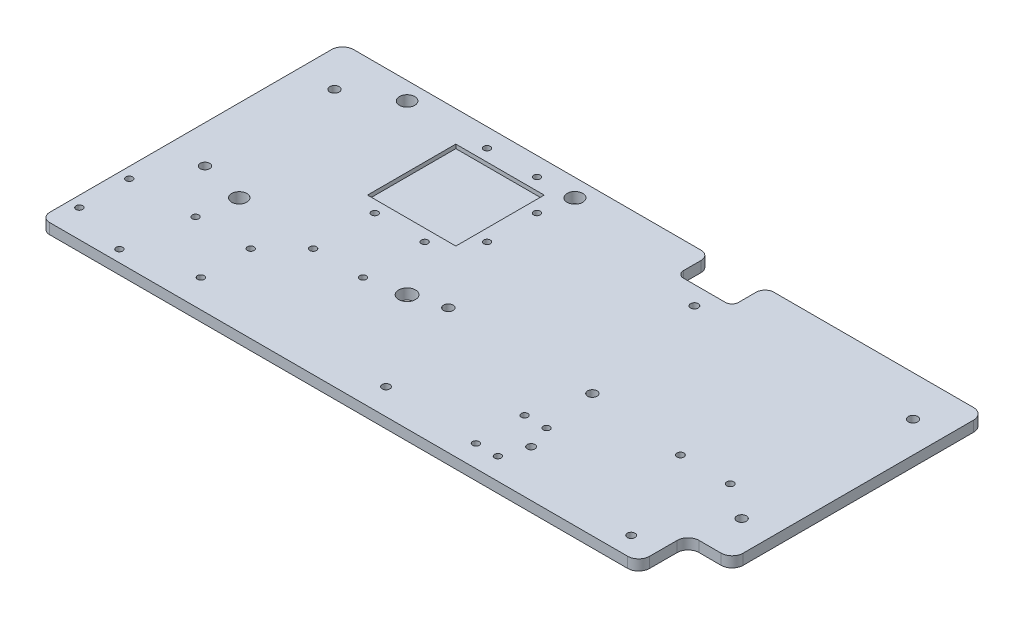
from build123d import *

# Parameters (mm, degrees)
SKETCH1_R           = 3.441866939
SKETCH1_R_2         = 3.819680327
SKETCH1_R_3         = 3.478478145
SKETCH1_R_4         = 3.546045212
SKETCH1_R_5         = 2.15
SKETCH1_R_6         = 1.75
SKETCH1_R_7         = 1.6
SKETCH1_R_8         = 1.5
BOSS_EXTRUDE1_DEPTH = 4.8
SKETCH8_W           = 40.1
SKETCH8_H           = 40.1
CUT_EXTRUDE3_DEPTH  = 1.8


with BuildPart() as part:
    # Sketch1 → Boss-Extrude1 (new body)
    with BuildSketch(Plane(origin=(0, 0, 0), x_dir=(1, 0, 0), z_dir=(0, 1, 0))):
        with BuildLine():
            Line((245, 5), (245, 17.432639589))
            ThreePointArc((245, 17.432639589), (246.464466094, 20.968173495), (250, 22.432639589))
            Line((250, 22.432639589), (260, 22.432639589))
            ThreePointArc((260, 22.432639589), (263.535533906, 23.897105683), (265, 27.432639589))
            Line((265, 27.432639589), (265, 132))
            ThreePointArc((265, 132), (263.535533906, 135.535533906), (260, 137))
            Line((260, 137), (169.363043016, 137))
            ThreePointArc((169.363043016, 137), (166.534615891, 135.828427125), (165.363043016, 133))
            Line((165.363043016, 133), (165.363043016, 125))
            ThreePointArc((165.363043016, 125), (164.48436336, 122.878679656), (162.363043016, 122))
            Line((162.363043016, 122), (143.363043016, 122))
            ThreePointArc((143.363043016, 122), (141.241722673, 122.878679656), (140.363043016, 125))
            Line((140.363043016, 125), (140.363043016, 133))
            ThreePointArc((140.363043016, 133), (139.191470141, 135.828427125), (136.363043016, 137))
            Line((136.363043016, 137), (-21.419472962, 137))
            ThreePointArc((-21.419472962, 137), (-24.955006868, 135.535533906), (-26.419472962, 132))
            Line((-26.419472962, 132), (-26.419472962, 4))
            ThreePointArc((-26.419472962, 4), (-25.247900086, 1.171572875), (-22.419472962, 0))
            Line((-22.419472962, 0), (0, 0))
            Line((0, 0), (240, 0))
            ThreePointArc((240, 0), (243.535533906, 1.464466094), (245, 5))
        make_face()
        with Locations((10.923340914, 52.745575572)):
            Circle(SKETCH1_R, mode=Mode.SUBTRACT)
        with Locations((87.123340914, 52.745575572)):
            Circle(SKETCH1_R_2, mode=Mode.SUBTRACT)
        with Locations((10.923340914, 128.945575572)):
            Circle(SKETCH1_R_3, mode=Mode.SUBTRACT)
        with Locations((87.123340914, 128.945575572)):
            Circle(SKETCH1_R_4, mode=Mode.SUBTRACT)
        with Locations((251.055268843, 40.693078652)):
            Circle(SKETCH1_R_5, mode=Mode.SUBTRACT)
        with Locations((250.907128745, 118.650785042)):
            Circle(SKETCH1_R_5, mode=Mode.SUBTRACT)
        with Locations((-9.383394869, 57.477183604)):
            Circle(SKETCH1_R_5, mode=Mode.SUBTRACT)
        with Locations((232.6, 9)):
            Circle(SKETCH1_R_6, mode=Mode.SUBTRACT)
        with Locations((-10.109931835, 117.018747652)):
            Circle(SKETCH1_R_5, mode=Mode.SUBTRACT)
        with Locations((175.026105079, 21.135490335)):
            Circle(SKETCH1_R_6, mode=Mode.SUBTRACT)
        with Locations((234.82067073, 51.7688297)):
            Circle(SKETCH1_R_7, mode=Mode.SUBTRACT)
        with Locations((212.16387073, 51.7688297)):
            Circle(SKETCH1_R_7, mode=Mode.SUBTRACT)
        with Locations((101.612778703, 56.992933905)):
            Circle(SKETCH1_R_5, mode=Mode.SUBTRACT)
        with Locations((168.022600915, 55.959262506)):
            Circle(SKETCH1_R_5, mode=Mode.SUBTRACT)
        with Locations((171.2, 32)):
            Circle(SKETCH1_R_8, mode=Mode.SUBTRACT)
        with Locations((171.2, 9.902)):
            Circle(SKETCH1_R_8, mode=Mode.SUBTRACT)
        with Locations((118.5, 11.8)):
            Circle(SKETCH1_R_6, mode=Mode.SUBTRACT)
        with Locations((161.2, 9.902)):
            Circle(SKETCH1_R_8, mode=Mode.SUBTRACT)
        with Locations((161.2, 32)):
            Circle(SKETCH1_R_8, mode=Mode.SUBTRACT)
        with Locations((156.7, 113.6)):
            Circle(SKETCH1_R_6, mode=Mode.SUBTRACT)
        with Locations((84.495, 114.3284)):
            Circle(SKETCH1_R_8, mode=Mode.SUBTRACT)
        with Locations((84.495, 91.6716)):
            Circle(SKETCH1_R_8, mode=Mode.SUBTRACT)
        with Locations((70.3284, 77.505)):
            Circle(SKETCH1_R_8, mode=Mode.SUBTRACT)
        with Locations((47.6716, 77.505)):
            Circle(SKETCH1_R_8, mode=Mode.SUBTRACT)
        with Locations((47.6716, 128.495)):
            Circle(SKETCH1_R_8, mode=Mode.SUBTRACT)
        with Locations((70.3284, 128.495)):
            Circle(SKETCH1_R_8, mode=Mode.SUBTRACT)
        with Locations((33.505, 12.7216)):
            Circle(SKETCH1_R_8, mode=Mode.SUBTRACT)
        with Locations((33.505, 35.3784)):
            Circle(SKETCH1_R_8, mode=Mode.SUBTRACT)
        with Locations((70.3284, 49.545)):
            Circle(SKETCH1_R_8, mode=Mode.SUBTRACT)
        with Locations((47.6716, 49.545)):
            Circle(SKETCH1_R_8, mode=Mode.SUBTRACT)
        with Locations((3.9, 5.3556)):
            Circle(SKETCH1_R_8, mode=Mode.SUBTRACT)
        with Locations((8.472, 35.353)):
            Circle(SKETCH1_R_8, mode=Mode.SUBTRACT)
        with Locations((-21.541231751, 12.61861449)):
            Circle(SKETCH1_R_8, mode=Mode.SUBTRACT)
        with Locations((-21.541231751, 35.27541449)):
            Circle(SKETCH1_R_8, mode=Mode.SUBTRACT)
    extrude(amount=BOSS_EXTRUDE1_DEPTH)

    # Sketch8 → Cut-Extrude3 (cut)
    with BuildSketch(Plane(origin=(0, 4.8, 0), x_dir=(1, 0, 0), z_dir=(0, 1, 0))):
        with Locations((59, 103)):
            Rectangle(SKETCH8_W, SKETCH8_H)
    extrude(amount=-CUT_EXTRUDE3_DEPTH, mode=Mode.SUBTRACT)


solid = part.part
